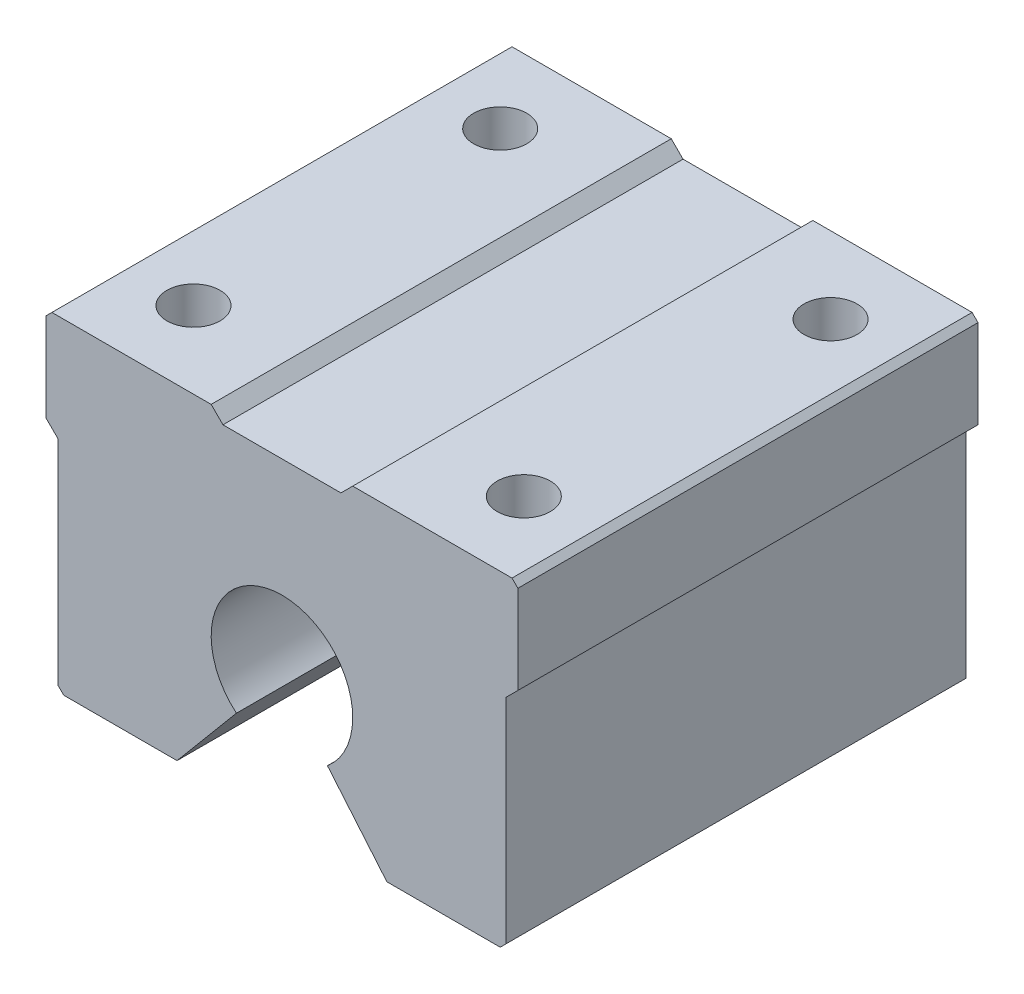
from build123d import *

# Parameters (mm, degrees)
EXTRUDE1_DEPTH = 39
SKETCH2_R      = 2.25
EXTRUDE2_DEPTH = 10


with BuildPart() as part:
    # Sketch1 → Extrude1 (new body)
    with BuildSketch(Plane.XY):
        with BuildLine():
            Line((-18.5, -13.8), (-8.89445609, -13.8))
            Line((-8.89445609, -13.8), (-3.856725658, -7.796266659))
            ThreePointArc((-3.856725658, -7.796266659), (0, 2.8), (3.856725658, -7.796266659))
            Line((3.856725658, -7.796266659), (8.89445609, -13.8))
            Line((8.89445609, -13.8), (18.5, -13.8))
            Line((18.5, -13.8), (19, -13.3))
            Line((19, -13.3), (19, 4.8))
            Line((19, 4.8), (20, 5.8))
            Line((20, 5.8), (20, 13.3))
            Line((20, 13.3), (19.5, 13.8))
            Line((19.5, 13.8), (6, 13.8))
            Line((6, 13.8), (5, 12.8))
            Line((5, 12.8), (-5, 12.8))
            Line((-5, 12.8), (-6, 13.8))
            Line((-6, 13.8), (-19.5, 13.8))
            Line((-19.5, 13.8), (-20, 13.3))
            Line((-20, 13.3), (-20, 5.8))
            Line((-20, 5.8), (-19, 4.8))
            Line((-19, 4.8), (-19, -13.3))
            Line((-19, -13.3), (-18.5, -13.8))
        make_face()
    extrude(amount=EXTRUDE1_DEPTH)

    # Sketch2 → Extrude2 (cut)
    with BuildSketch(Plane(origin=(0, 13.8, 0), x_dir=(1, 0, 0), z_dir=(0, 1, 0))):
        with Locations((-14, -6.5)):
            Circle(SKETCH2_R)
        with Locations((-14, -32.5)):
            Circle(SKETCH2_R)
        with Locations((14, -32.5)):
            Circle(SKETCH2_R)
        with Locations((14, -6.5)):
            Circle(SKETCH2_R)
    extrude(amount=-EXTRUDE2_DEPTH, mode=Mode.SUBTRACT)


solid = part.part
